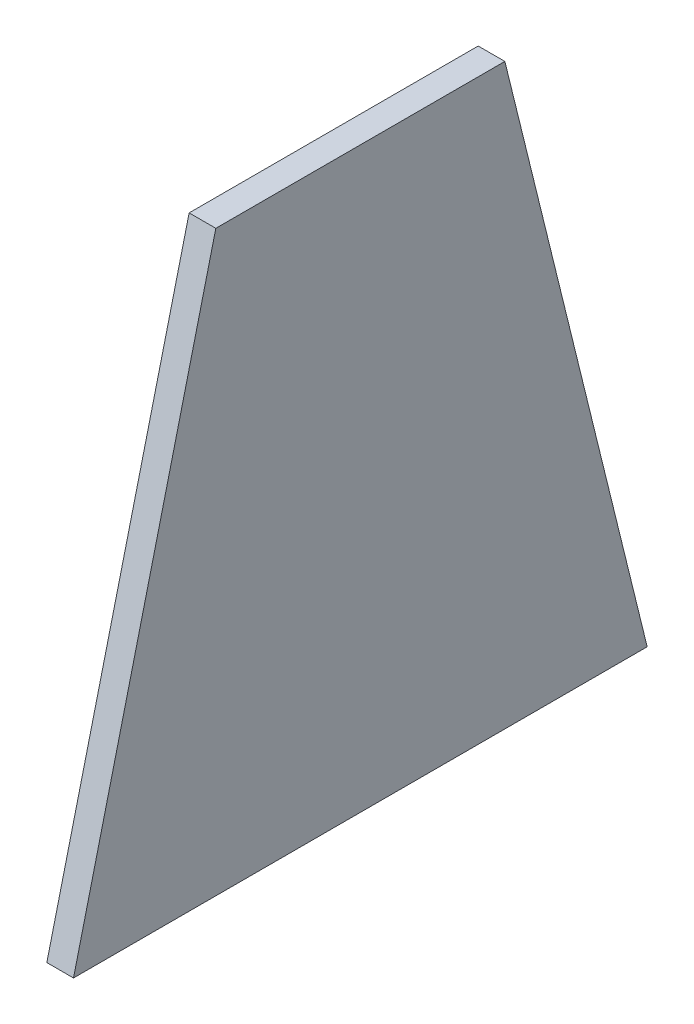
from build123d import *

# Parameters (mm, degrees)
SALIENTE_EXTRUIR1_DEPTH = 3


with BuildPart() as part:
    # Croquis2 → Saliente-Extruir1 (new body)
    with BuildSketch(Plane(origin=(0, 0, 0), x_dir=(0, 0, -1), z_dir=(1, 0, 0))):
        Polygon((-15.105796306, 33.438278854), (17.394203694, 33.438278854), (33.394203694, -31.561721146), (-31.105796306, -31.561721146), align=None)
    extrude(amount=SALIENTE_EXTRUIR1_DEPTH)


solid = part.part
